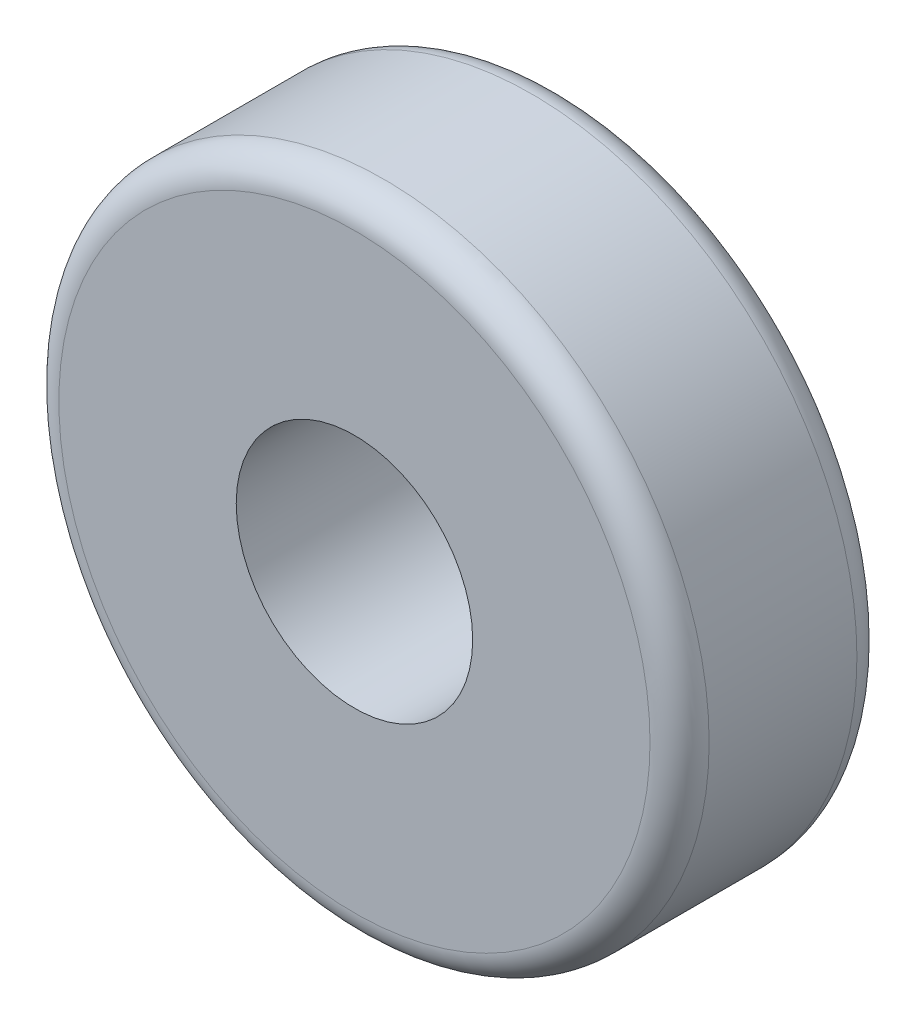
from build123d import *

# Parameters (mm, degrees)
ESBO_O1_R                = 11
ESBO_O1_R_2              = 4
RESSALTO_EXTRUS_O1_DEPTH = 7
FILETE1_R                = 1


with BuildPart() as part:
    # Esboço1 → Ressalto-extrusão1 (new body)
    with BuildSketch(Plane.XY):
        Circle(ESBO_O1_R)
        Circle(ESBO_O1_R_2, mode=Mode.SUBTRACT)
    extrude(amount=RESSALTO_EXTRUS_O1_DEPTH)

    # Filete1
    filete1_edges = [part.edges().sort_by_distance(p)[0] for p in [
        (-11, 0, 0),
        (-11, 0, 7),
    ]]
    fillet(filete1_edges, radius=FILETE1_R)


solid = part.part
